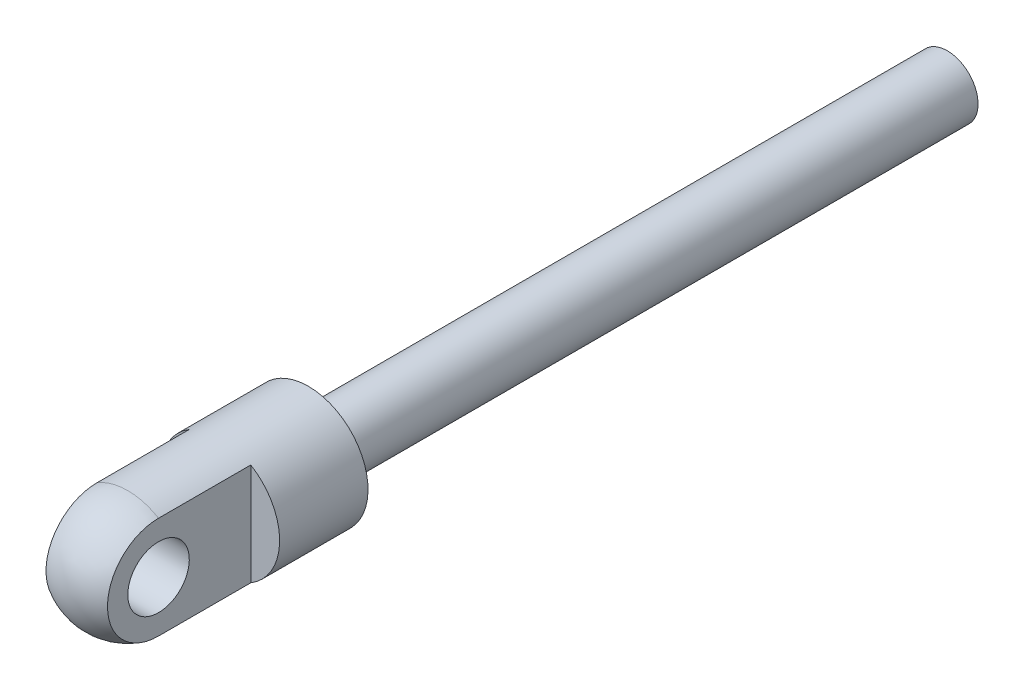
from build123d import *

# Parameters (mm, degrees)
FILLET2_R               = 0.77724
SKETCH2_R               = 2.032
EXTRUDE2_DEPTH          = 2.032
SKETCH9_W               = 42.2148
SKETCH9_H               = 2.032
SKETCH12_R              = 2.032
CUT_EXTRUDE1_DEPTH      = 6.9690001
CUT_EXTRUDE1_DEPTH_BACK = 6.9690001
SKETCH13_OUTSIDE_W      = 37.724
SKETCH13_OUTSIDE_H      = 37.724
SKETCH13_OUTSIDE_W_2    = 4.064
SKETCH13_OUTSIDE_H_2    = 7.874
CUT_EXTRUDE2_DEPTH      = 4.937
CUT_EXTRUDE2_DEPTH_BACK = 6.096
LPATTERN1_COUNT         = 2
LPATTERN1_PITCH         = 29.972


with BuildPart() as part:
    # Sketch1 → Revolve1 (revolve)
    with BuildSketch(Plane(origin=(0, 0, 0), x_dir=(0, 0, -1), z_dir=(1, 0, 0))):
        Polygon((46.609, 0), (46.609, 5.969), (-13.0302, 5.969), (-13.0302, 2.0828), (16.9926, 2.0828), (29.1846, 2.0828), (29.1846, 0), align=None)
    revolve(axis=Axis((0, 0, 54.991), (0, 0, -1)))

    # Fillet2
    fillet2_edges = [part.edges().sort_by_distance(p)[0] for p in [
        (0, -5.969, 13.0302),
        (0, -5.969, -46.609),
    ]]
    fillet(fillet2_edges, radius=FILLET2_R)

    # Sketch2 → Extrude2 (add, symmetric)
    with BuildSketch(Plane(origin=(0, 0, 0), x_dir=(0, 0, -1), z_dir=(1, 0, 0))):
        with BuildLine():
            Line((46.609, 3.81), (54.991, 3.81))
            ThreePointArc((54.991, 3.81), (58.801, 0), (54.991, -3.81))
            Line((54.991, -3.81), (46.609, -3.81))
            Line((46.609, -3.81), (46.609, 3.81))
        make_face()
        with Locations((54.991, 0)):
            Circle(SKETCH2_R, mode=Mode.SUBTRACT)
    extrude(amount=EXTRUDE2_DEPTH, both=True)


with BuildPart() as body_2:
    # Sketch9 → Revolve5 (revolve)
    with BuildSketch(Plane(origin=(0, 0, 0), x_dir=(0, 0, -1), z_dir=(1, 0, 0))):
        with Locations((-21.9456, 1.016)):
            Rectangle(SKETCH9_W, SKETCH9_H)
    revolve(axis=Axis((0, 0, 43.053), (0, 0, 1)))

    # Sketch11 → Revolve6 (revolve)
    with BuildSketch(Plane(origin=(0, 0, 0), x_dir=(0, 0, -1), z_dir=(1, 0, 0))):
        with BuildLine():
            Line((-43.053, 0), (-43.053, 3.937))
            Line((-43.053, 3.937), (-54.991, 3.937))
            ThreePointArc((-54.991, 3.937), (-57.774879398, 2.783879398), (-58.928, 0))
            Line((-58.928, 0), (-43.053, 0))
        make_face()
    revolve(axis=Axis((0, 0, 58.928), (0, 0, 1)))

    # Sketch12 → Cut-Extrude1 (cut, two sides)
    with BuildSketch(Plane(origin=(0, 0, 0), x_dir=(0, 0, -1), z_dir=(1, 0, 0))) as cut_extrude1_sk:
        with Locations((-54.991, 0)):
            Circle(SKETCH12_R)
    extrude(amount=CUT_EXTRUDE1_DEPTH, mode=Mode.SUBTRACT)
    extrude(cut_extrude1_sk.sketch, amount=-CUT_EXTRUDE1_DEPTH_BACK, mode=Mode.SUBTRACT)

    # Sketch13 outside → Cut-Extrude2 (cut, two sides)
    with BuildSketch(Plane.XY.offset(54.991)) as cut_extrude2_sk:
        Rectangle(SKETCH13_OUTSIDE_W, SKETCH13_OUTSIDE_H)
        Rectangle(SKETCH13_OUTSIDE_W_2, SKETCH13_OUTSIDE_H_2, mode=Mode.SUBTRACT)
    extrude(amount=CUT_EXTRUDE2_DEPTH, mode=Mode.SUBTRACT)
    extrude(cut_extrude2_sk.sketch, amount=-CUT_EXTRUDE2_DEPTH_BACK, mode=Mode.SUBTRACT)


with BuildPart() as lpattern1_1:
    # LPattern1: pattern copy
    add(body_2.part.moved(Location(Vector(0, 0, -1) * (1 * LPATTERN1_PITCH))))


solid = lpattern1_1.part
